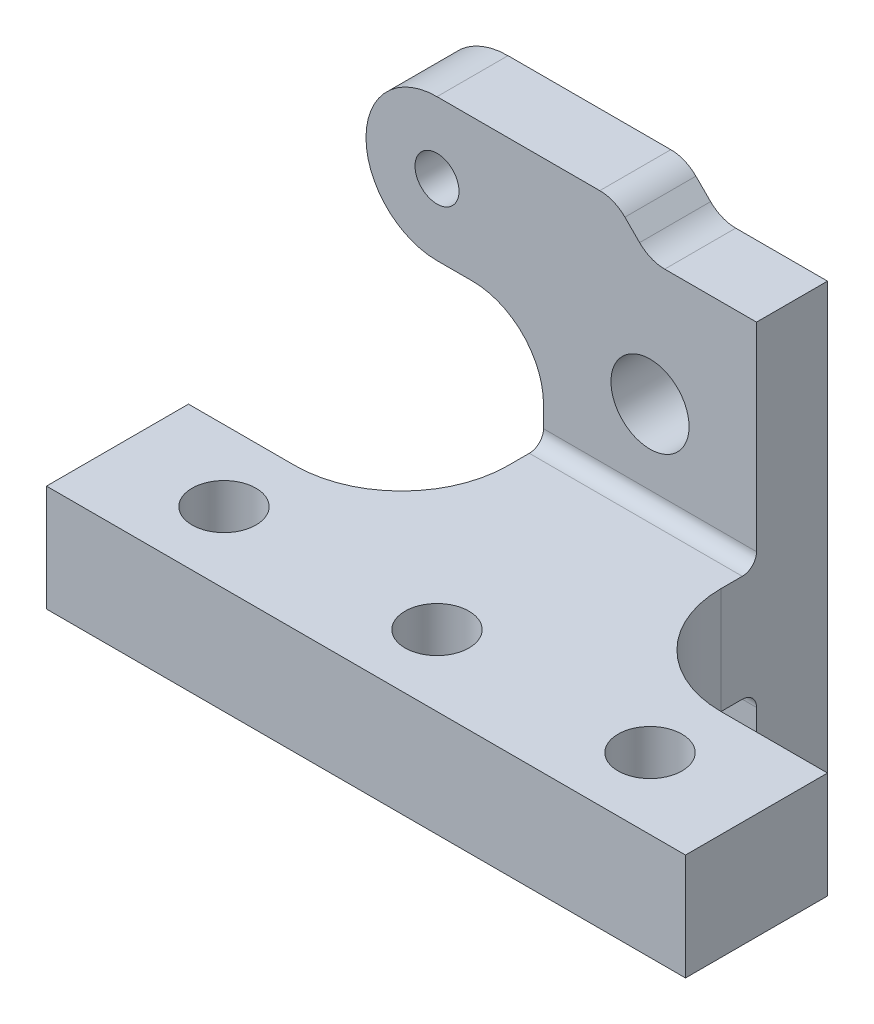
from build123d import *

# Parameters (mm, degrees)
SKETCH_1_W          = 30
SKETCH_1_H          = 75
SKETCH_1_R          = 5.5
EXTRUDE_1_DEPTH     = 10
SKETCH_2_W          = 30
SKETCH_2_H          = 15
EXTRUDE_2_DEPTH     = 40
FILLET_1_R          = 2
SKETCH_3_R          = 4.5
CUT_EXTRUDE_1_DEPTH = 15
SKETCH_5_W          = 20
SKETCH_5_H          = 15
EXTRUDE_3_DEPTH     = 30
SKETCH_6_R          = 4.5
CUT_EXTRUDE_2_DEPTH = 30
FILLET_2_R          = 15
SKETCH_7_W          = 20
SKETCH_7_H          = 15
EXTRUDE_4_DEPTH     = 30
FILLET_3_R          = 15
SKETCH_8_R          = 4.5
CUT_EXTRUDE_3_DEPTH = 30
EXTRUDE_5_DEPTH     = 10
FILLET_4_R          = 5
FILLET_5_R          = 10
SKETCH_10_R         = 3.1
CUT_EXTRUDE_4_DEPTH = 10


with BuildPart() as part:
    # 草图1 → 凸台-拉伸1 (new body)
    with BuildSketch(Plane.XY):
        Rectangle(SKETCH_1_W, SKETCH_1_H)
        with Locations((0, 20)):
            Circle(SKETCH_1_R, mode=Mode.SUBTRACT)
        with Locations((0, -20)):
            Circle(SKETCH_1_R, mode=Mode.SUBTRACT)
    extrude(amount=EXTRUDE_1_DEPTH)

    # 草图2 → 凸台-拉伸2 (add)
    with BuildSketch(Plane.XY.offset(10)):
        Rectangle(SKETCH_2_W, SKETCH_2_H)
    extrude(amount=EXTRUDE_2_DEPTH)

    # 圆角1
    fillet_1_edges = [part.edges().sort_by_distance(p)[0] for p in [
        (0, 7.5, 10),
        (0, -7.5, 10),
    ]]
    fillet(fillet_1_edges, radius=FILLET_1_R)

    # 草图3 → 切除-拉伸1 (cut)
    with BuildSketch(Plane(origin=(0, -7.5, 0), x_dir=(-1, 0, 0), z_dir=(0, -1, 0))):
        with Locations((0, -40)):
            Circle(SKETCH_3_R)
    extrude(amount=-CUT_EXTRUDE_1_DEPTH, mode=Mode.SUBTRACT)

    # 草图5 → 凸台-拉伸3 (add)
    with BuildSketch(Plane(origin=(15, 0, 0), x_dir=(0, 0, -1), z_dir=(1, 0, 0))):
        with Locations((-40, 0)):
            Rectangle(SKETCH_5_W, SKETCH_5_H)
    extrude(amount=EXTRUDE_3_DEPTH)

    # 草图6 → 切除-拉伸2 (cut)
    with BuildSketch(Plane(origin=(0, -7.5, 0), x_dir=(-1, 0, 0), z_dir=(0, -1, 0))):
        with Locations((-30, -40)):
            Circle(SKETCH_6_R)
    extrude(amount=-CUT_EXTRUDE_2_DEPTH, mode=Mode.SUBTRACT)

    # 圆角2
    fillet_2_edges = [part.edges().sort_by_distance(p)[0] for p in [
        (15, 0, 30),
    ]]
    fillet(fillet_2_edges, radius=FILLET_2_R)

    # 草图7 → 凸台-拉伸4 (add)
    with BuildSketch(Plane.ZY.offset(15)):
        with Locations((40, 0)):
            Rectangle(SKETCH_7_W, SKETCH_7_H)
    extrude(amount=EXTRUDE_4_DEPTH)

    # 圆角3
    fillet_3_edges = [part.edges().sort_by_distance(p)[0] for p in [
        (-15, 0, 30),
    ]]
    fillet(fillet_3_edges, radius=FILLET_3_R)

    # 草图8 → 切除-拉伸3 (cut)
    with BuildSketch(Plane(origin=(0, -7.5, 0), x_dir=(-1, 0, 0), z_dir=(0, -1, 0))):
        with Locations((30, -40)):
            Circle(SKETCH_8_R)
    extrude(amount=-CUT_EXTRUDE_3_DEPTH, mode=Mode.SUBTRACT)

    # 草图9 → 凸台-拉伸5 (add)
    with BuildSketch(Plane.XY.offset(10)):
        with BuildLine():
            Line((-30, 42.5), (-5, 42.5))
            Line((-5, 42.5), (0, 37.5))
            Line((0, 37.5), (-15, 22.5))
            Line((-15, 22.5), (-30, 22.5))
            ThreePointArc((-30, 22.5), (-40, 32.5), (-30, 42.5))
        make_face()
    extrude(amount=-EXTRUDE_5_DEPTH)

    # 圆角4
    fillet_4_edges = [part.edges().sort_by_distance(p)[0] for p in [
        (-5, 42.5, 5),
        (0, 37.5, 5),
    ]]
    fillet(fillet_4_edges, radius=FILLET_4_R)

    # 圆角5
    fillet_5_edges = [part.edges().sort_by_distance(p)[0] for p in [
        (-15, 22.5, 5),
    ]]
    fillet(fillet_5_edges, radius=FILLET_5_R)

    # 草图10 → 切除-拉伸4 (cut)
    with BuildSketch(Plane.XY.offset(10)):
        with Locations((-30, 32.5)):
            Circle(SKETCH_10_R)
    extrude(amount=-CUT_EXTRUDE_4_DEPTH, mode=Mode.SUBTRACT)


solid = part.part
